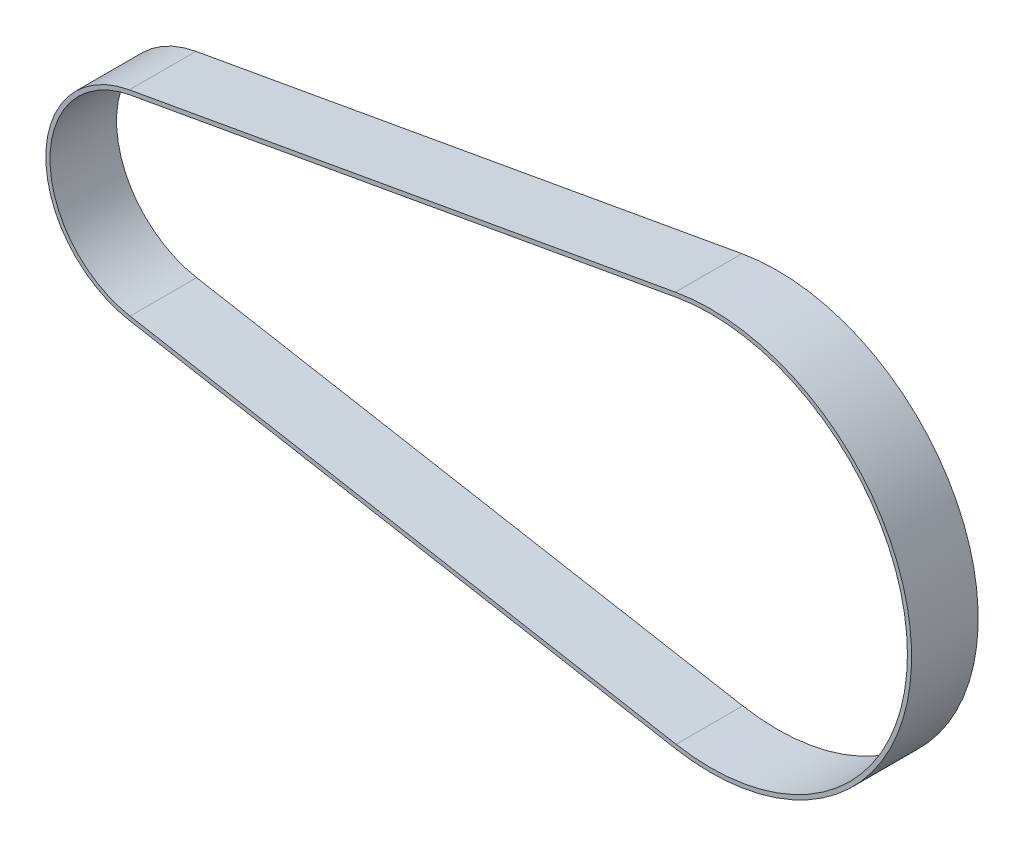
from build123d import *

# Parameters (mm, degrees)
BOSS_EXTRUDE1_DEPTH = 16


with BuildPart() as part:
    # Sketch1 → Boss-Extrude1 (new body)
    with BuildSketch(Plane(origin=(0, 0, -8), x_dir=(-1, 0, 0), z_dir=(0, 0, -1))):
        with BuildLine():
            Line((8.507292851, -47.490515719), (139.687441775, -23.991340645))
            ThreePointArc((139.687441775, -23.991340645), (159.762954363, 0), (139.687441775, 23.991340645))
            Line((139.687441775, 23.991340645), (8.507292851, 47.490515719))
            ThreePointArc((8.507292851, 47.490515719), (-48.246482928, 0), (8.507292851, -47.490515719))
        make_face()
        with BuildLine():
            Line((8.330963048, 46.506184575), (139.511111972, 23.007009502))
            ThreePointArc((139.511111972, 23.007009502), (158.762954363, 0), (139.511111972, -23.007009502))
            Line((139.511111972, -23.007009502), (8.330963048, -46.506184575))
            ThreePointArc((8.330963048, -46.506184575), (-47.246482928, 0), (8.330963048, 46.506184575))
        make_face(mode=Mode.SUBTRACT)
    extrude(amount=-BOSS_EXTRUDE1_DEPTH)


solid = part.part
